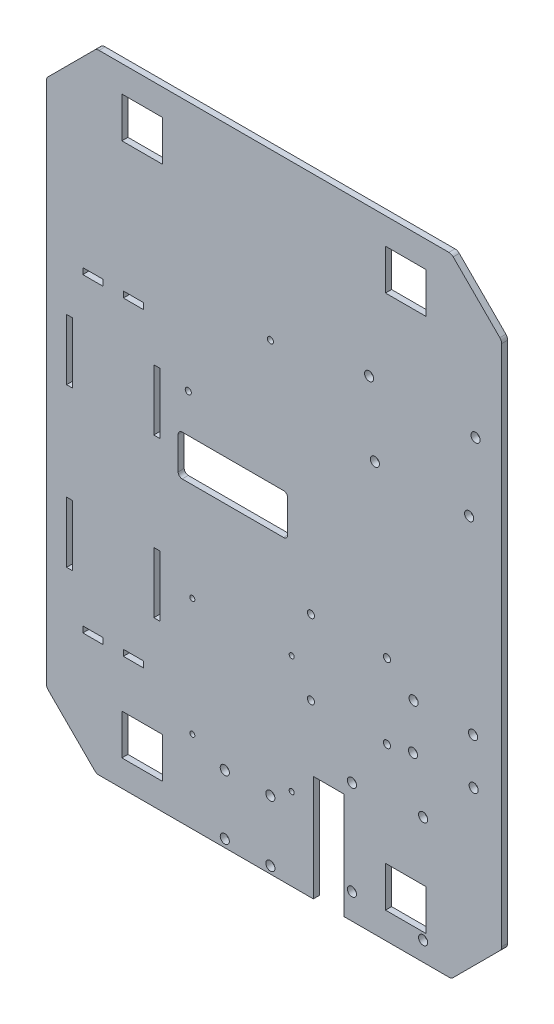
from build123d import *

# Parameters (mm, degrees)
BASE_DEPTH              = 3
ESQUISSE2_W             = 20
ESQUISSE2_H             = 20
ENL_V_MAT_EXTRU_1_DEPTH = 4
CONG_1_R                = 3
ESQUISSE4_R             = 1.25
ESQUISSE4_R_2           = 1.5
ENL_V_MAT_EXTRU_4_DEPTH = 4
ENL_V_MAT_EXTRU_5_REACH = 5
ESQUISSE5_R             = 2.25
ESQUISSE5_W             = 15.031140496
ESQUISSE5_H             = 52.322618027
PONT_H_MAL_PLACE_2_R    = 1.75
PONT_H_MAL_PLACE_DEPTH  = 3
ESQUISSE10_W            = 10
ESQUISSE10_H            = 3
ESQUISSE10_W_2          = 3
ESQUISSE10_H_2          = 30
ENL_V_MAT_EXTRU_7_DEPTH = 3


with BuildPart() as part:
    # Esquisse1 → Base (new body)
    with BuildSketch(Plane.XY):
        Polygon((0, 0), (-175, 0), (-199.748737342, 24.748737342), (-199.748737342, 284.748737342), (-175, 309.497474683), (0, 309.497474683), (24.748737342, 284.748737342), (24.748737342, 24.748737342), align=None)
    extrude(amount=BASE_DEPTH)

    # Esquisse2 → Enlèv. mat.-Extru.1 (cut, through all)
    with BuildSketch(Plane.XY.offset(3)):
        with Locations((-152.5, 286.497474683)):
            Rectangle(ESQUISSE2_W, ESQUISSE2_H)
        with Locations((-152.5, 23)):
            Rectangle(ESQUISSE2_W, ESQUISSE2_H)
        with Locations((-22.5, 23)):
            Rectangle(ESQUISSE2_W, ESQUISSE2_H)
        with Locations((-22.5, 286.497474683)):
            Rectangle(ESQUISSE2_W, ESQUISSE2_H)
    extrude(amount=-ENL_V_MAT_EXTRU_1_DEPTH, mode=Mode.SUBTRACT)

    # Congé1
    cong_1_edges = [part.edges().sort_by_distance(p)[0] for p in [
        (0, 0, 1.5),
        (-175, 0, 1.5),
        (-199.748737342, 24.748737342, 1.5),
        (-199.748737342, 284.748737342, 1.5),
        (-175, 309.497474683, 1.5),
        (0, 309.497474683, 1.5),
        (24.748737342, 284.748737342, 1.5),
        (24.748737342, 24.748737342, 1.5),
    ]]
    fillet(cong_1_edges, radius=CONG_1_R)

    # Esquisse4 → Enlèv. mat.-Extru.4 (cut, through all)
    with BuildSketch(Plane.XY.offset(3)):
        with Locations((-78.748737342, 98.497474683)):
            Circle(ESQUISSE4_R)
        with Locations((-127.748737342, 98.497474683)):
            Circle(ESQUISSE4_R)
        with Locations((-78.748737342, 40.497474683)):
            Circle(ESQUISSE4_R)
        with Locations((-127.748737342, 40.497474683)):
            Circle(ESQUISSE4_R)
        with Locations((-129.748737342, 185.997474683)):
            Circle(ESQUISSE4_R_2)
        with Locations((-89.248737342, 227.997474683)):
            Circle(ESQUISSE4_R_2)
        with BuildLine():
            Line((-82.748737342, 166.997474683), (-132.748737342, 166.997474683))
            ThreePointArc((-132.748737342, 166.997474683), (-134.162950904, 166.411688245), (-134.748737342, 164.997474683))
            Line((-134.748737342, 164.997474683), (-134.748737342, 148.997474683))
            ThreePointArc((-134.748737342, 148.997474683), (-134.162950904, 147.583261121), (-132.748737342, 146.997474683))
            Line((-132.748737342, 146.997474683), (-82.748737342, 146.997474683))
            ThreePointArc((-82.748737342, 146.997474683), (-81.334523779, 147.583261121), (-80.748737342, 148.997474683))
            Line((-80.748737342, 148.997474683), (-80.748737342, 164.997474683))
            ThreePointArc((-80.748737342, 164.997474683), (-81.334523779, 166.411688245), (-82.748737342, 166.997474683))
        make_face()
    extrude(amount=-ENL_V_MAT_EXTRU_4_DEPTH, mode=Mode.SUBTRACT)

    # Esquisse5 → Enlèv. mat.-Extru.5 (cut, up to next)
    with BuildSketch(Plane.XY.offset(3), mode=Mode.PRIVATE) as enl_v_mat_extru_5_sk1:
        with Locations((-111.738429941, 3.832493236)):
            Circle(ESQUISSE5_R)
    enl_v_mat_extru_5_tool1 = extrude(enl_v_mat_extru_5_sk1.sketch, amount=-ENL_V_MAT_EXTRU_5_REACH, mode=Mode.PRIVATE) & part.part
    add(enl_v_mat_extru_5_tool1.solids().sort_by_distance((-111.73843, 3.832493, 3))[0], mode=Mode.SUBTRACT)
    # Esquisse5 → Enlèv. mat.-Extru.5 (cut, up to next)
    with BuildSketch(Plane.XY.offset(3), mode=Mode.PRIVATE) as enl_v_mat_extru_5_sk2:
        with Locations((-89.268885084, 3.53845203)):
            Circle(ESQUISSE5_R)
    enl_v_mat_extru_5_tool2 = extrude(enl_v_mat_extru_5_sk2.sketch, amount=-ENL_V_MAT_EXTRU_5_REACH, mode=Mode.PRIVATE) & part.part
    add(enl_v_mat_extru_5_tool2.solids().sort_by_distance((-89.268885, 3.538452, 3))[0], mode=Mode.SUBTRACT)
    # Esquisse5 → Enlèv. mat.-Extru.5 (cut, up to next)
    with BuildSketch(Plane.XY.offset(3), mode=Mode.PRIVATE) as enl_v_mat_extru_5_sk3:
        with Locations((-89.268885084, 33.46154797)):
            Circle(ESQUISSE5_R)
    enl_v_mat_extru_5_tool3 = extrude(enl_v_mat_extru_5_sk3.sketch, amount=-ENL_V_MAT_EXTRU_5_REACH, mode=Mode.PRIVATE) & part.part
    add(enl_v_mat_extru_5_tool3.solids().sort_by_distance((-89.268885, 33.461548, 3))[0], mode=Mode.SUBTRACT)
    # Esquisse5 → Enlèv. mat.-Extru.5 (cut, up to next)
    with BuildSketch(Plane.XY.offset(3), mode=Mode.PRIVATE) as enl_v_mat_extru_5_sk4:
        with Locations((-111.738429941, 33.167506764)):
            Circle(ESQUISSE5_R)
    enl_v_mat_extru_5_tool4 = extrude(enl_v_mat_extru_5_sk4.sketch, amount=-ENL_V_MAT_EXTRU_5_REACH, mode=Mode.PRIVATE) & part.part
    add(enl_v_mat_extru_5_tool4.solids().sort_by_distance((-111.73843, 33.167507, 3))[0], mode=Mode.SUBTRACT)
    # Esquisse5 → Enlèv. mat.-Extru.5 (cut, up to next)
    with BuildSketch(Plane.XY.offset(3), mode=Mode.PRIVATE) as enl_v_mat_extru_5_sk5:
        with Locations((-49.05, 12.640927164)):
            Circle(ESQUISSE5_R)
    enl_v_mat_extru_5_tool5 = extrude(enl_v_mat_extru_5_sk5.sketch, amount=-ENL_V_MAT_EXTRU_5_REACH, mode=Mode.PRIVATE) & part.part
    add(enl_v_mat_extru_5_tool5.solids().sort_by_distance((-49.05, 12.640927, 3))[0], mode=Mode.SUBTRACT)
    # Esquisse5 → Enlèv. mat.-Extru.5 (cut, up to next)
    with BuildSketch(Plane.XY.offset(3), mode=Mode.PRIVATE) as enl_v_mat_extru_5_sk6:
        with Locations((-13.95, 9.5)):
            Circle(ESQUISSE5_R)
    enl_v_mat_extru_5_tool6 = extrude(enl_v_mat_extru_5_sk6.sketch, amount=-ENL_V_MAT_EXTRU_5_REACH, mode=Mode.PRIVATE) & part.part
    add(enl_v_mat_extru_5_tool6.solids().sort_by_distance((-13.95, 9.5, 3))[0], mode=Mode.SUBTRACT)
    # Esquisse5 → Enlèv. mat.-Extru.5 (cut, up to next)
    with BuildSketch(Plane.XY.offset(3), mode=Mode.PRIVATE) as enl_v_mat_extru_5_sk7:
        with Locations((-49.05, 59.140927164)):
            Circle(ESQUISSE5_R)
    enl_v_mat_extru_5_tool7 = extrude(enl_v_mat_extru_5_sk7.sketch, amount=-ENL_V_MAT_EXTRU_5_REACH, mode=Mode.PRIVATE) & part.part
    add(enl_v_mat_extru_5_tool7.solids().sort_by_distance((-49.05, 59.140927, 3))[0], mode=Mode.SUBTRACT)
    # Esquisse5 → Enlèv. mat.-Extru.5 (cut, up to next)
    with BuildSketch(Plane.XY.offset(3), mode=Mode.PRIVATE) as enl_v_mat_extru_5_sk8:
        with Locations((-13.95, 61.981854328)):
            Circle(ESQUISSE5_R)
    enl_v_mat_extru_5_tool8 = extrude(enl_v_mat_extru_5_sk8.sketch, amount=-ENL_V_MAT_EXTRU_5_REACH, mode=Mode.PRIVATE) & part.part
    add(enl_v_mat_extru_5_tool8.solids().sort_by_distance((-13.95, 61.981854, 3))[0], mode=Mode.SUBTRACT)
    # Esquisse5 → Enlèv. mat.-Extru.5 (cut, up to next)
    with BuildSketch(Plane.XY.offset(3), mode=Mode.PRIVATE) as enl_v_mat_extru_5_sk9:
        with Locations((8.748737342, 201.897474683)):
            Circle(ESQUISSE5_R)
    enl_v_mat_extru_5_tool9 = extrude(enl_v_mat_extru_5_sk9.sketch, amount=-ENL_V_MAT_EXTRU_5_REACH, mode=Mode.PRIVATE) & part.part
    add(enl_v_mat_extru_5_tool9.solids().sort_by_distance((8.748737, 201.897475, 3))[0], mode=Mode.SUBTRACT)
    # Esquisse5 → Enlèv. mat.-Extru.5 (cut, up to next)
    with BuildSketch(Plane.XY.offset(3), mode=Mode.PRIVATE) as enl_v_mat_extru_5_sk10:
        with Locations((11.889664506, 236.997474683)):
            Circle(ESQUISSE5_R)
    enl_v_mat_extru_5_tool10 = extrude(enl_v_mat_extru_5_sk10.sketch, amount=-ENL_V_MAT_EXTRU_5_REACH, mode=Mode.PRIVATE) & part.part
    add(enl_v_mat_extru_5_tool10.solids().sort_by_distance((11.889665, 236.997475, 3))[0], mode=Mode.SUBTRACT)
    # Esquisse5 → Enlèv. mat.-Extru.5 (cut, up to next)
    with BuildSketch(Plane.XY.offset(3), mode=Mode.PRIVATE) as enl_v_mat_extru_5_sk11:
        with Locations((-37.751262658, 201.897474683)):
            Circle(ESQUISSE5_R)
    enl_v_mat_extru_5_tool11 = extrude(enl_v_mat_extru_5_sk11.sketch, amount=-ENL_V_MAT_EXTRU_5_REACH, mode=Mode.PRIVATE) & part.part
    add(enl_v_mat_extru_5_tool11.solids().sort_by_distance((-37.751263, 201.897475, 3))[0], mode=Mode.SUBTRACT)
    # Esquisse5 → Enlèv. mat.-Extru.5 (cut, up to next)
    with BuildSketch(Plane.XY.offset(3), mode=Mode.PRIVATE) as enl_v_mat_extru_5_sk12:
        with Locations((-40.592189823, 236.997474683)):
            Circle(ESQUISSE5_R)
    enl_v_mat_extru_5_tool12 = extrude(enl_v_mat_extru_5_sk12.sketch, amount=-ENL_V_MAT_EXTRU_5_REACH, mode=Mode.PRIVATE) & part.part
    add(enl_v_mat_extru_5_tool12.solids().sort_by_distance((-40.59219, 236.997475, 3))[0], mode=Mode.SUBTRACT)
    # Esquisse5 → Enlèv. mat.-Extru.5 (cut, up to next)
    with BuildSketch(Plane.XY.offset(3), mode=Mode.PRIVATE) as enl_v_mat_extru_5_sk13:
        with Locations((-18.655958793, 109.451399186)):
            Circle(ESQUISSE5_R)
    enl_v_mat_extru_5_tool13 = extrude(enl_v_mat_extru_5_sk13.sketch, amount=-ENL_V_MAT_EXTRU_5_REACH, mode=Mode.PRIVATE) & part.part
    add(enl_v_mat_extru_5_tool13.solids().sort_by_distance((-18.655959, 109.451399, 3))[0], mode=Mode.SUBTRACT)
    # Esquisse5 → Enlèv. mat.-Extru.5 (cut, up to next)
    with BuildSketch(Plane.XY.offset(3), mode=Mode.PRIVATE) as enl_v_mat_extru_5_sk14:
        with Locations((-18.95, 86.981854328)):
            Circle(ESQUISSE5_R)
    enl_v_mat_extru_5_tool14 = extrude(enl_v_mat_extru_5_sk14.sketch, amount=-ENL_V_MAT_EXTRU_5_REACH, mode=Mode.PRIVATE) & part.part
    add(enl_v_mat_extru_5_tool14.solids().sort_by_distance((-18.95, 86.981854, 3))[0], mode=Mode.SUBTRACT)
    # Esquisse5 → Enlèv. mat.-Extru.5 (cut, up to next)
    with BuildSketch(Plane.XY.offset(3), mode=Mode.PRIVATE) as enl_v_mat_extru_5_sk15:
        with Locations((10.973095941, 86.981854328)):
            Circle(ESQUISSE5_R)
    enl_v_mat_extru_5_tool15 = extrude(enl_v_mat_extru_5_sk15.sketch, amount=-ENL_V_MAT_EXTRU_5_REACH, mode=Mode.PRIVATE) & part.part
    add(enl_v_mat_extru_5_tool15.solids().sort_by_distance((10.973096, 86.981854, 3))[0], mode=Mode.SUBTRACT)
    # Esquisse5 → Enlèv. mat.-Extru.5 (cut, up to next)
    with BuildSketch(Plane.XY.offset(3), mode=Mode.PRIVATE) as enl_v_mat_extru_5_sk16:
        with Locations((10.679054734, 109.451399186)):
            Circle(ESQUISSE5_R)
    enl_v_mat_extru_5_tool16 = extrude(enl_v_mat_extru_5_sk16.sketch, amount=-ENL_V_MAT_EXTRU_5_REACH, mode=Mode.PRIVATE) & part.part
    add(enl_v_mat_extru_5_tool16.solids().sort_by_distance((10.679055, 109.451399, 3))[0], mode=Mode.SUBTRACT)
    # Esquisse5 → Enlèv. mat.-Extru.5 (cut, up to next)
    with BuildSketch(Plane.XY.offset(3), mode=Mode.PRIVATE) as enl_v_mat_extru_5_sk17:
        with Locations((-60.577832016, 26.161309014)):
            Rectangle(ESQUISSE5_W, ESQUISSE5_H)
    enl_v_mat_extru_5_tool17 = extrude(enl_v_mat_extru_5_sk17.sketch, amount=-ENL_V_MAT_EXTRU_5_REACH, mode=Mode.PRIVATE) & part.part
    add(enl_v_mat_extru_5_tool17.solids().sort_by_distance((-60.577832, 26.161309, 3))[0], mode=Mode.SUBTRACT)

    # PONT H mal place 2 → pont_H_mal_place (cut)
    with BuildSketch(Plane.XY.offset(3)):
        with Locations((-69.262539319, 120.947398703)):
            Circle(PONT_H_MAL_PLACE_2_R)
        with Locations((-69.262539319, 84.205598383)):
            Circle(PONT_H_MAL_PLACE_2_R)
        with Locations((-31.776164099, 84.205598383)):
            Circle(PONT_H_MAL_PLACE_2_R)
        with Locations((-31.776164099, 120.947398703)):
            Circle(PONT_H_MAL_PLACE_2_R)
    extrude(amount=-PONT_H_MAL_PLACE_DEPTH, mode=Mode.SUBTRACT)

    # Esquisse10 → Enlèv. mat.-Extru.7 (cut)
    with BuildSketch(Plane.XY.offset(3)):
        with Locations((-176.748737342, 58.248737342)):
            Rectangle(ESQUISSE10_W, ESQUISSE10_H)
        with Locations((-188.248737342, 95.748737342)):
            Rectangle(ESQUISSE10_W_2, ESQUISSE10_H_2)
        with Locations((-156.748737342, 58.248737342)):
            Rectangle(ESQUISSE10_W, ESQUISSE10_H)
        with Locations((-145.248737342, 95.748737342)):
            Rectangle(ESQUISSE10_W_2, ESQUISSE10_H_2)
        with Locations((-188.248737342, 173.748737342)):
            Rectangle(ESQUISSE10_W_2, ESQUISSE10_H_2)
        with Locations((-156.748737342, 211.248737342)):
            Rectangle(ESQUISSE10_W, ESQUISSE10_H)
        with Locations((-176.748737342, 211.248737342)):
            Rectangle(ESQUISSE10_W, ESQUISSE10_H)
        with Locations((-145.248737342, 173.748737342)):
            Rectangle(ESQUISSE10_W_2, ESQUISSE10_H_2)
    extrude(amount=-ENL_V_MAT_EXTRU_7_DEPTH, mode=Mode.SUBTRACT)


solid = part.part
